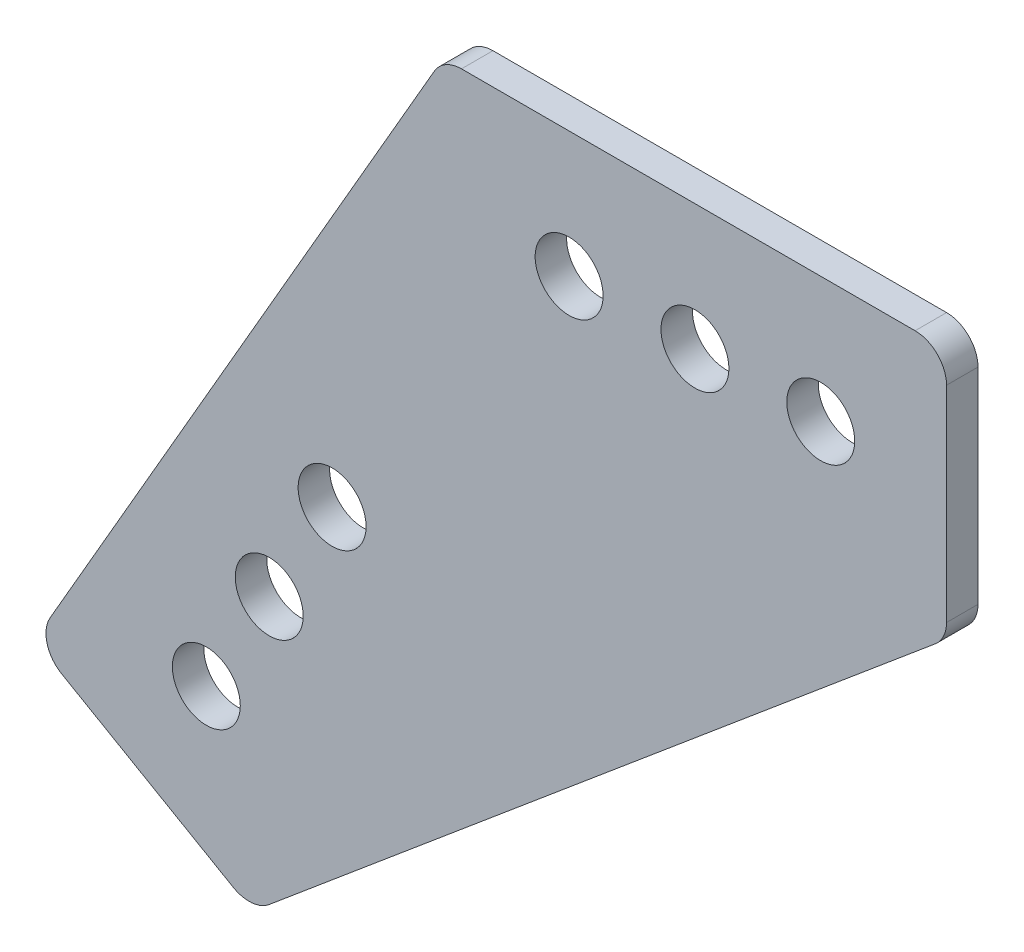
from build123d import *

# Parameters (mm, degrees)
SKETCH1_R           = 3.429
BOSS_EXTRUDE1_DEPTH = 3.175
FILLET1_R           = 3.175


with BuildPart() as part:
    # Sketch1 → Boss-Extrude1 (new body)
    with BuildSketch(Plane.XY):
        Polygon((0, 0), (50.8, 0), (50.8, -25.4), (-19.277954744, -84.190397082), (-41.275, -71.490397082), align=None)
        with Locations((38.1, -12.7)):
            Circle(SKETCH1_R, mode=Mode.SUBTRACT)
        with Locations((25.4, -12.7)):
            Circle(SKETCH1_R, mode=Mode.SUBTRACT)
        with Locations((12.7, -12.7)):
            Circle(SKETCH1_R, mode=Mode.SUBTRACT)
        with Locations((-23.926477372, -66.841874454)):
            Circle(SKETCH1_R, mode=Mode.SUBTRACT)
        with Locations((-17.576477372, -55.843351826)):
            Circle(SKETCH1_R, mode=Mode.SUBTRACT)
        with Locations((-11.226477372, -44.844829198)):
            Circle(SKETCH1_R, mode=Mode.SUBTRACT)
    extrude(amount=BOSS_EXTRUDE1_DEPTH)

    # Fillet1
    fillet1_edges = [part.edges().sort_by_distance(p)[0] for p in [
        (0, 0, 1.5875),
        (50.8, 0, 1.5875),
        (50.8, -25.4, 1.5875),
        (-19.277954744, -84.190397082, 1.5875),
        (-41.275, -71.490397082, 1.5875),
    ]]
    fillet(fillet1_edges, radius=FILLET1_R)


solid = part.part
